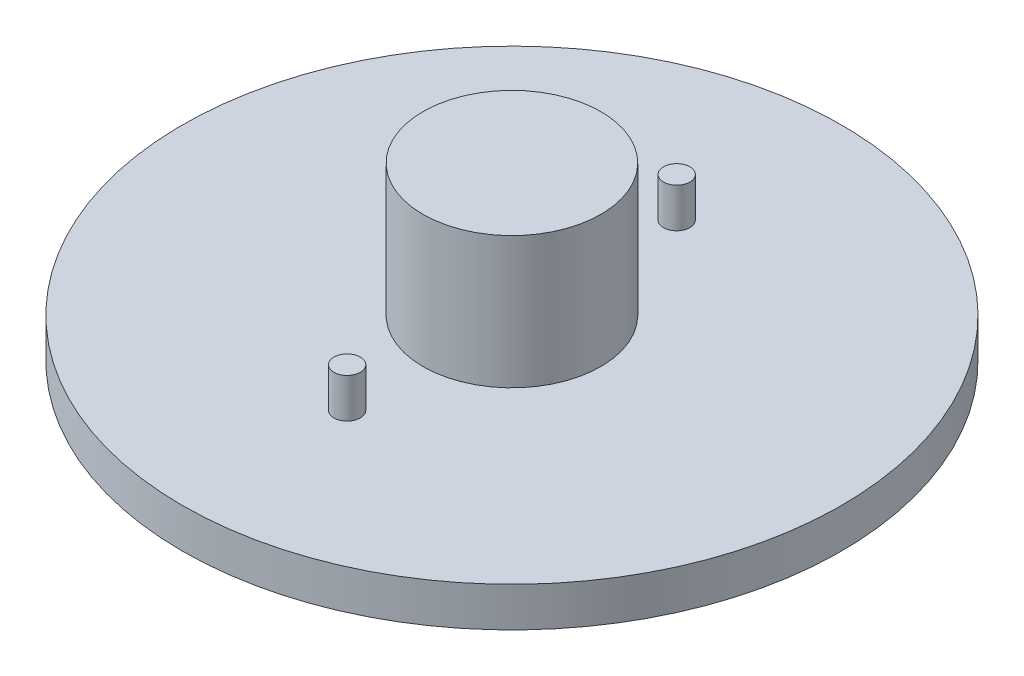
from build123d import *

# Parameters (mm, degrees)
ESQUISSE2_R        = 2
BOSS_EXTRU_1_DEPTH = 6
BOSS_EXTRU_2_DEPTH = 25


with BuildPart() as part:
    # Esquisse1 → Révolution4 (revolve)
    with BuildSketch(Plane.XY):
        Polygon((-5.618645861, -7.271198097), (35.881354139, -7.271198097), (35.881354139, -1.271198097), (-0.618645861, -1.271198097), (-0.618645861, 18.728801903), (-14.118645861, 18.728801903), (-14.118645861, 14.081661898), (-5.618645861, 14.081661898), align=None)
    revolve(axis=Axis((-14.118645861, 18.728801903, 0), (0, -1, 0)))

    # Esquisse2 → Boss.-Extru.1 (add)
    with BuildSketch(Plane(origin=(0, -1.271198097, 0), x_dir=(1, 0, 0), z_dir=(0, 1, 0))):
        with Locations((-14.118645861, -25)):
            Circle(ESQUISSE2_R)
        with Locations((-14.118645861, 25)):
            Circle(ESQUISSE2_R)
    extrude(amount=BOSS_EXTRU_1_DEPTH)

    # Esquisse3 → Boss.-Extru.2 (add)
    with BuildSketch(Plane.XZ.offset(7.271198097)):
        with BuildLine():
            ThreePointArc((-7.618645861, -5.477225575), (-6.13428615, -2.915475947), (-5.618645861, 0))
            ThreePointArc((-5.618645861, 0), (-6.13428615, 2.915475947), (-7.618645861, 5.477225575))
            Line((-7.618645861, 5.477225575), (-7.618645861, 0))
            Line((-7.618645861, 0), (-7.618645861, -5.477225575))
        make_face()
    extrude(amount=-BOSS_EXTRU_2_DEPTH)


solid = part.part
